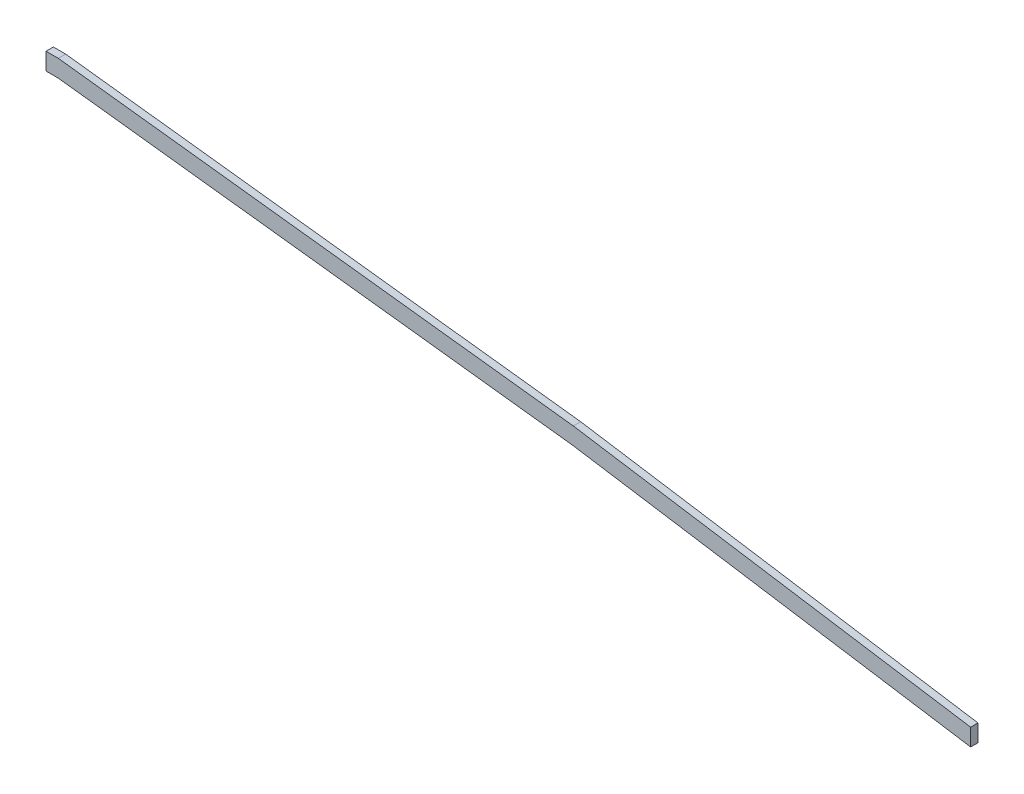
from build123d import *

# Parameters (mm, degrees)
BOSS_EXTRUDE1_DEPTH = 3


with BuildPart() as part:
    # Sketch1 → Boss-Extrude1 (new body)
    with BuildSketch(Plane.XY):
        Polygon((0, -7), (210, -31.817973337), (372, -57.186496339), (372, -50.186496339), (210, -24.817973337), (0, 0), (-5, 0), (-5, -7), align=None)
    extrude(amount=BOSS_EXTRUDE1_DEPTH)


solid = part.part
